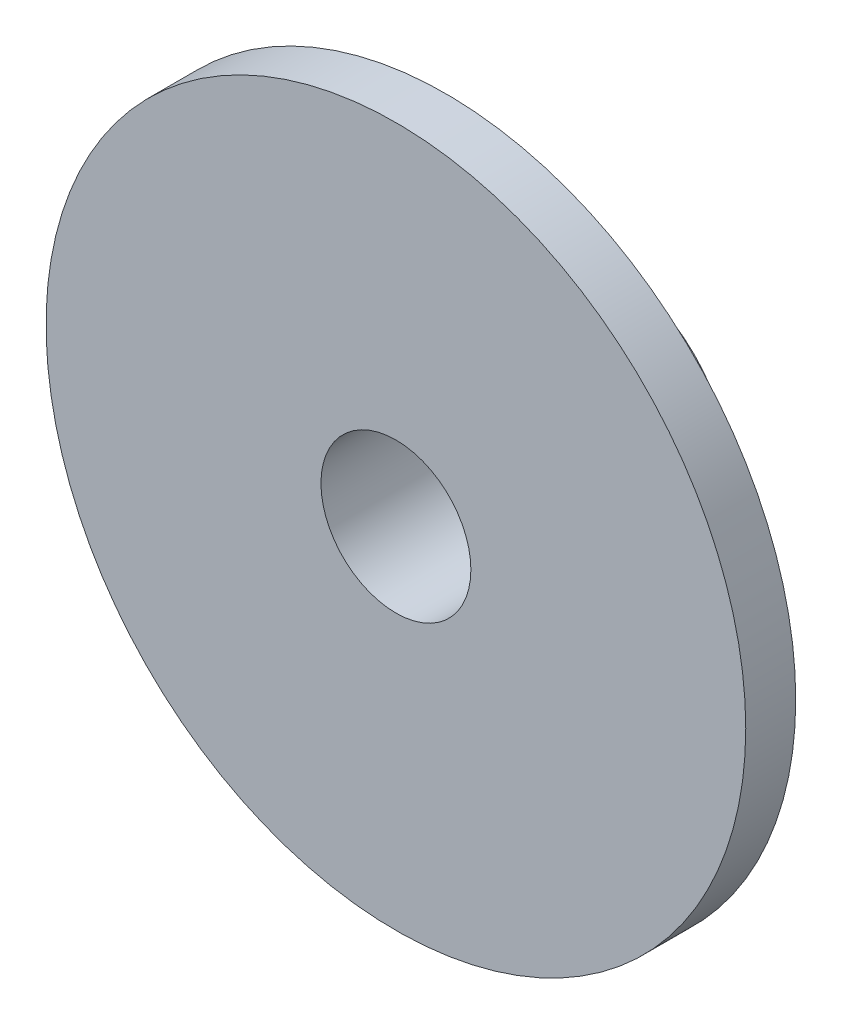
from build123d import *

# Parameters (mm, degrees)
SKETCH1_R           = 22.225
SKETCH1_R_2         = 4.7625
BOSS_EXTRUDE1_DEPTH = 3.175
SKETCH2_R           = 7.9375
SKETCH2_R_2         = 4.7625
BOSS_EXTRUDE2_DEPTH = 10.16


with BuildPart() as part:
    # Sketch1 → Boss-Extrude1 (new body)
    with BuildSketch(Plane.XY):
        Circle(SKETCH1_R)
        Circle(SKETCH1_R_2, mode=Mode.SUBTRACT)
    extrude(amount=BOSS_EXTRUDE1_DEPTH)

    # Sketch2 → Boss-Extrude2 (add)
    with BuildSketch(Plane(origin=(0, 0, 0), x_dir=(-1, 0, 0), z_dir=(0, 0, -1))):
        Circle(SKETCH2_R)
        Circle(SKETCH2_R_2, mode=Mode.SUBTRACT)
    extrude(amount=BOSS_EXTRUDE2_DEPTH)


solid = part.part
